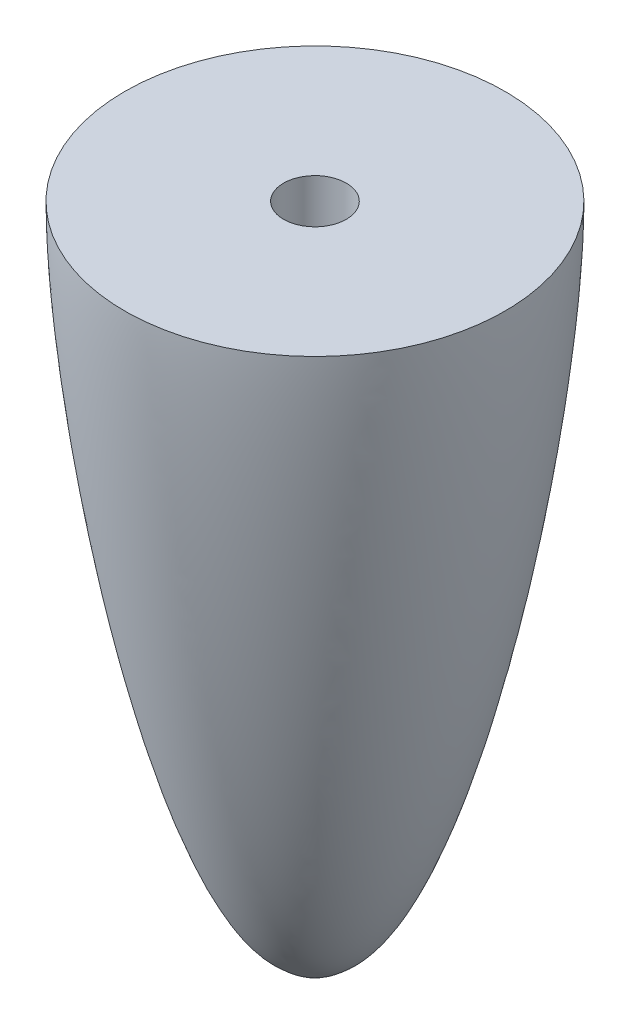
from build123d import *

# Parameters (mm, degrees)
TROU_TARAUD_M41_D     = 3.3
TROU_TARAUD_M41_DEPTH = 22
TROU_TARAUD_M41_TIP   = 0.991420021


with BuildPart() as part:
    # Esquisse5 → Révolution1 (revolve)
    with BuildSketch(Plane.XY):
        with BuildLine():
            Line((0, 14), (0, -21))
            add(Edge.make_bspline(
                [(-1.5, -20.3), (-1.460203942, -20.331876133), (-0.662919651, -20.964459536), (-0.207667434, -21), (0, -21)],
                knots=[0, 0, 0, 0, 0.05, 1, 1, 1, 1], degree=3))
            add(Edge.make_bspline(
                [(-10, 14), (-10, 5.648701911), (-6.488485569, -16.06311059), (-1.7516567, -20.098426203), (-1.5, -20.3)],
                knots=[0, 0, 0, 0, 0.95, 1, 1, 1, 1], degree=3))
            Line((-10, 14), (0, 14))
        make_face()
    revolve(axis=Axis((0, 14, 0), (0, -1, 0)))

    # Trou taraudé M41
    with Locations(Plane(origin=(0, 14, 0), x_dir=(1, 0, 0), z_dir=(0, 1, 0))):
        with Locations((0, 0)):
            Hole(TROU_TARAUD_M41_D / 2, depth=TROU_TARAUD_M41_DEPTH)
            with Locations((0, 0, -(TROU_TARAUD_M41_DEPTH + TROU_TARAUD_M41_TIP / 2))):  # 118° drill point
                Cone(0, TROU_TARAUD_M41_D / 2, TROU_TARAUD_M41_TIP, mode=Mode.SUBTRACT)


solid = part.part
